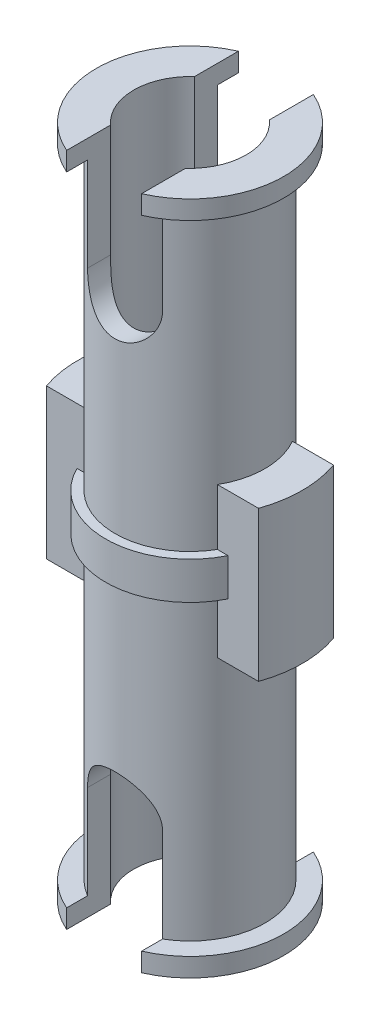
from build123d import *

# Parameters (mm, degrees)
SKETCH3_W               = 6
SKETCH3_H               = 4
BOSS_EXTRUDE4_DEPTH     = 1
CUT_EXTRUDE2_DEPTH      = 3.5
CUT_EXTRUDE2_DEPTH_BACK = 3.5
SKETCH6_R               = 1.5
CUT_EXTRUDE3_DEPTH      = 18
SKETCH7_OUTSIDE_W       = 11.904
SKETCH7_OUTSIDE_H       = 10.486
SKETCH7_OUTSIDE_R       = 3
CUT_EXTRUDE4_DEPTH      = 10.0000001
CUT_EXTRUDE4_DEPTH_BACK = 10.0000001


with BuildPart() as part:
    # Sketch1 → Revolve5 (revolve)
    with BuildSketch(Plane.XY):
        Polygon((0, 9), (-2.5, 9), (-2.5, 8.5), (-2, 8.5), (-2, 0.5), (-2.25, 0.5), (-2.25, -0.5), (-2, -0.5), (-2, -8.5), (-2.5, -8.5), (-2.5, -9), (0, -9), align=None)
    revolve(axis=Axis((0, 9, 0), (0, -1, 0)))

    # Sketch3 → Boss-Extrude4 (add, symmetric)
    with BuildSketch(Plane.XY):
        Rectangle(SKETCH3_W, SKETCH3_H)
    extrude(amount=BOSS_EXTRUDE4_DEPTH, both=True)

    # Sketch5 → Cut-Extrude2 (cut, two sides)
    with BuildSketch(Plane.XY) as cut_extrude2_sk:
        with BuildLine():
            Line((-1, 9), (-1, 6))
            ThreePointArc((-1, 6), (0, 5), (1, 6))
            Line((1, 6), (1, 9))
            Line((1, 9), (-1, 9))
        make_face()
        with BuildLine():
            Line((-1, -9), (-1, -6))
            ThreePointArc((-1, -6), (0, -5), (1, -6))
            Line((1, -6), (1, -9))
            Line((1, -9), (-1, -9))
        make_face()
    extrude(amount=CUT_EXTRUDE2_DEPTH, mode=Mode.SUBTRACT)
    extrude(cut_extrude2_sk.sketch, amount=-CUT_EXTRUDE2_DEPTH_BACK, mode=Mode.SUBTRACT)

    # Sketch6 → Cut-Extrude3 (cut)
    with BuildSketch(Plane(origin=(0, 9, 0), x_dir=(1, 0, 0), z_dir=(0, 1, 0))):
        Circle(SKETCH6_R)
    extrude(amount=-CUT_EXTRUDE3_DEPTH, mode=Mode.SUBTRACT)

    # Sketch7 outside → Cut-Extrude4 (cut, two sides)
    with BuildSketch(Plane(origin=(0, 0, 0), x_dir=(1, 0, 0), z_dir=(0, 1, 0))) as cut_extrude4_sk:
        Rectangle(SKETCH7_OUTSIDE_W, SKETCH7_OUTSIDE_H)
        Circle(SKETCH7_OUTSIDE_R, mode=Mode.SUBTRACT)
    extrude(amount=CUT_EXTRUDE4_DEPTH, mode=Mode.SUBTRACT)
    extrude(cut_extrude4_sk.sketch, amount=-CUT_EXTRUDE4_DEPTH_BACK, mode=Mode.SUBTRACT)


solid = part.part
